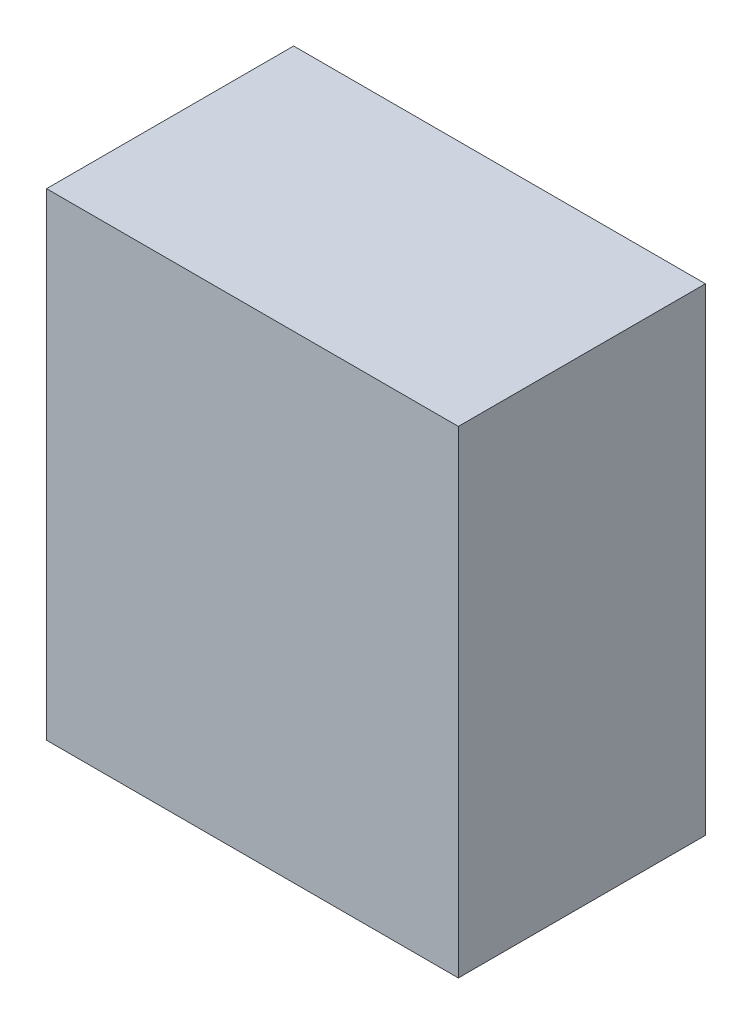
from build123d import *

# Parameters (mm, degrees)
SKETCH1_W           = 10
SKETCH1_H           = 6
BOSS_EXTRUDE1_DEPTH = 11.6


with BuildPart() as part:
    # Sketch1 → Boss-Extrude1 (new body)
    with BuildSketch(Plane(origin=(0, 0, 0), x_dir=(1, 0, 0), z_dir=(0, 1, 0))):
        Rectangle(SKETCH1_W, SKETCH1_H)
    extrude(amount=BOSS_EXTRUDE1_DEPTH)


solid = part.part
